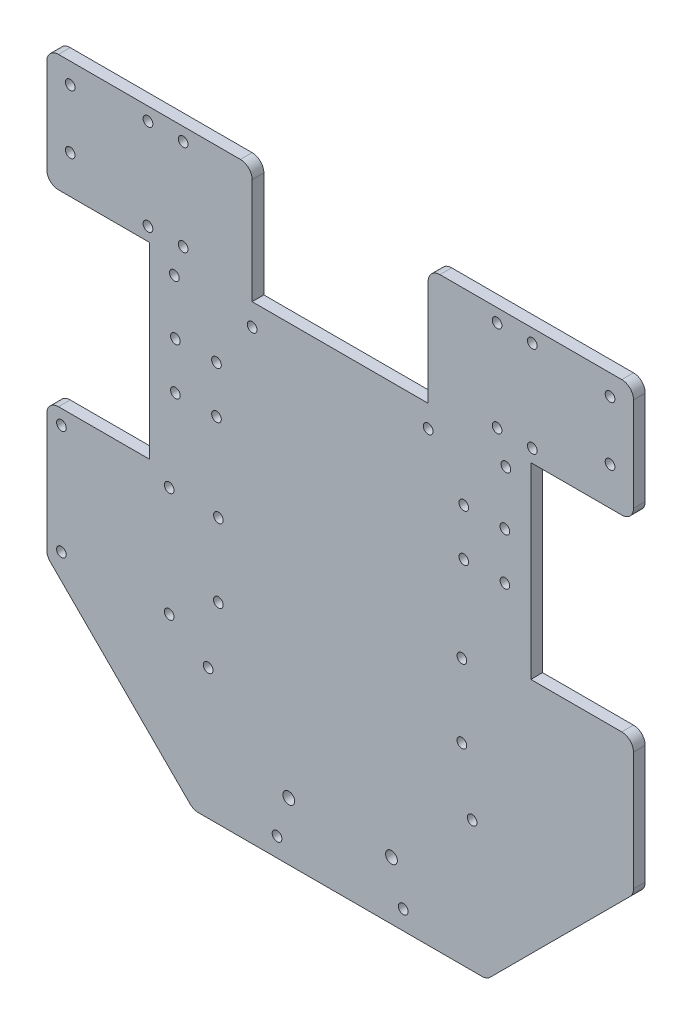
from build123d import *

# Parameters (mm, degrees)
EXTRUDE_1_DEPTH      = 4
SKETCH_4_R           = 1.65
CUT_EXTRUDE_5_DEPTH  = 10
SKETCH_5_R           = 1.65
CUT_EXTRUDE_6_DEPTH  = 10
SKETCH_6_R           = 1.65
CUT_EXTRUDE_7_DEPTH  = 10
SKETCH_7_R           = 1.65
CUT_EXTRUDE_8_DEPTH  = 10
SKETCH_8_R           = 2
CUT_EXTRUDE_9_DEPTH  = 10
SKETCH_9_R           = 1.65
CUT_EXTRUDE_10_DEPTH = 10
SKETCH_10_R          = 1.65
CUT_EXTRUDE_11_DEPTH = 10
SKETCH_11_R          = 1.65
CUT_EXTRUDE_12_DEPTH = 10
SKETCH_12_R          = 1.65
CUT_EXTRUDE_13_DEPTH = 10
FILLET_1_R           = 4
FILLET_2_R           = 4


with BuildPart() as part:
    # 草图1 → 凸台-拉伸1 (new body)
    with BuildSketch(Plane.XY):
        with BuildLine():
            Line((-96, 200), (-30, 200))
            Line((-30, 200), (-30, 160))
            Line((-30, 160), (30, 160))
            Line((30, 160), (30, 200))
            Line((30, 200), (96, 200))
            ThreePointArc((96, 200), (98.828427125, 198.828427125), (100, 196))
            Line((100, 196), (100, 160))
            Line((100, 160), (65, 160))
            Line((65, 160), (65, 96))
            Line((65, 96), (100, 96))
            Line((100, 96), (100, 50))
            Line((100, 50), (50, 0))
            Line((50, 0), (-50, 0))
            Line((-50, 0), (-100, 50))
            Line((-100, 50), (-100, 96))
            Line((-100, 96), (-65, 96))
            Line((-65, 96), (-65, 160))
            Line((-65, 160), (-100, 160))
            Line((-100, 160), (-100, 196))
            ThreePointArc((-100, 196), (-98.828427125, 198.828427125), (-96, 200))
        make_face()
    extrude(amount=EXTRUDE_1_DEPTH)

    # 草图4 → 切除-拉伸5 (cut)
    with BuildSketch(Plane(origin=(0, 0, 0), x_dir=(-1, 0, 0), z_dir=(0, 0, -1))):
        with Locations((56.5, 154.5)):
            Circle(SKETCH_4_R)
        with Locations((-56.5, 154.5)):
            Circle(SKETCH_4_R)
        with Locations((45, 44.5)):
            Circle(SKETCH_4_R)
        with Locations((-45, 44.5)):
            Circle(SKETCH_4_R)
    extrude(amount=-CUT_EXTRUDE_5_DEPTH, mode=Mode.SUBTRACT)

    # 草图5 → 切除-拉伸6 (cut)
    with BuildSketch(Plane(origin=(0, 0, 0), x_dir=(-1, 0, 0), z_dir=(0, 0, -1))):
        with Locations((41.5, 90.5)):
            Circle(SKETCH_5_R)
        with Locations((-41.5, 90.5)):
            Circle(SKETCH_5_R)
        with Locations((41.5, 65.5)):
            Circle(SKETCH_5_R)
        with Locations((-41.5, 65.5)):
            Circle(SKETCH_5_R)
    extrude(amount=-CUT_EXTRUDE_6_DEPTH, mode=Mode.SUBTRACT)

    # 草图6 → 切除-拉伸7 (cut)
    with BuildSketch(Plane(origin=(0, 0, 0), x_dir=(-1, 0, 0), z_dir=(0, 0, -1))):
        with Locations((58.26, 91)):
            Circle(SKETCH_6_R)
        with Locations((95, 91)):
            Circle(SKETCH_6_R)
        with Locations((58.26, 53.62)):
            Circle(SKETCH_6_R)
        with Locations((95, 53.62)):
            Circle(SKETCH_6_R)
    extrude(amount=-CUT_EXTRUDE_7_DEPTH, mode=Mode.SUBTRACT)

    # 草图7 → 切除-拉伸8 (cut)
    with BuildSketch(Plane(origin=(0, 0, 0), x_dir=(-1, 0, 0), z_dir=(0, 0, -1))):
        with Locations((-21.5, 6.5)):
            Circle(SKETCH_7_R)
        with Locations((21.5, 6.5)):
            Circle(SKETCH_7_R)
    extrude(amount=-CUT_EXTRUDE_8_DEPTH, mode=Mode.SUBTRACT)

    # 草图8 → 切除-拉伸9 (cut)
    with BuildSketch(Plane(origin=(0, 0, 0), x_dir=(-1, 0, 0), z_dir=(0, 0, -1))):
        with Locations((-17.5, 19.75)):
            Circle(SKETCH_8_R)
        with Locations((17.5, 19.75)):
            Circle(SKETCH_8_R)
    extrude(amount=-CUT_EXTRUDE_9_DEPTH, mode=Mode.SUBTRACT)

    # 草图9 → 切除-拉伸10 (cut)
    with BuildSketch(Plane(origin=(0, 0, 0), x_dir=(-1, 0, 0), z_dir=(0, 0, -1))):
        with Locations((-30, 152.5)):
            Circle(SKETCH_9_R)
        with Locations((30, 152.5)):
            Circle(SKETCH_9_R)
    extrude(amount=-CUT_EXTRUDE_10_DEPTH, mode=Mode.SUBTRACT)

    # 草图10 → 切除-拉伸11 (cut)
    with BuildSketch(Plane.XY.offset(4)):
        with Locations((-92, 193)):
            Circle(SKETCH_10_R)
        with Locations((-92, 173)):
            Circle(SKETCH_10_R)
        with Locations((92, 173)):
            Circle(SKETCH_10_R)
        with Locations((92, 193)):
            Circle(SKETCH_10_R)
    extrude(amount=-CUT_EXTRUDE_11_DEPTH, mode=Mode.SUBTRACT)

    # 草图11 → 切除-拉伸12 (cut)
    with BuildSketch(Plane.XY.offset(4)):
        with Locations((65.5, 164.5)):
            Circle(SKETCH_11_R)
        with Locations((53.5, 164.5)):
            Circle(SKETCH_11_R)
        with Locations((53.5, 195.5)):
            Circle(SKETCH_11_R)
        with Locations((65.5, 195.5)):
            Circle(SKETCH_11_R)
        with Locations((-65.5, 195.5)):
            Circle(SKETCH_11_R)
        with Locations((-53.5, 195.5)):
            Circle(SKETCH_11_R)
        with Locations((-53.5, 164.5)):
            Circle(SKETCH_11_R)
        with Locations((-65.5, 164.5)):
            Circle(SKETCH_11_R)
    extrude(amount=-CUT_EXTRUDE_12_DEPTH, mode=Mode.SUBTRACT)

    # 草图12 → 切除-拉伸13 (cut)
    with BuildSketch(Plane.XY.offset(4)):
        with Locations((56.15, 120)):
            Circle(SKETCH_12_R)
        with Locations((42.15, 120)):
            Circle(SKETCH_12_R)
        with Locations((42.15, 136)):
            Circle(SKETCH_12_R)
        with Locations((56.15, 136)):
            Circle(SKETCH_12_R)
        with Locations((-56.15, 136)):
            Circle(SKETCH_12_R)
        with Locations((-42.15, 136)):
            Circle(SKETCH_12_R)
        with Locations((-42.15, 120)):
            Circle(SKETCH_12_R)
        with Locations((-56.15, 120)):
            Circle(SKETCH_12_R)
    extrude(amount=-CUT_EXTRUDE_13_DEPTH, mode=Mode.SUBTRACT)

    # 圆角1
    fillet_1_edges = [part.edges().sort_by_distance(p)[0] for p in [
        (100, 160, 2),
        (100, 96, 2),
        (100, 50, 2),
        (50, 0, 2),
        (-50, 0, 2),
        (-100, 50, 2),
        (-100, 96, 2),
        (-100, 160, 2),
    ]]
    fillet(fillet_1_edges, radius=FILLET_1_R)

    # 圆角2
    fillet_2_edges = [part.edges().sort_by_distance(p)[0] for p in [
        (-30, 200, 2),
        (30, 200, 2),
    ]]
    fillet(fillet_2_edges, radius=FILLET_2_R)


solid = part.part
